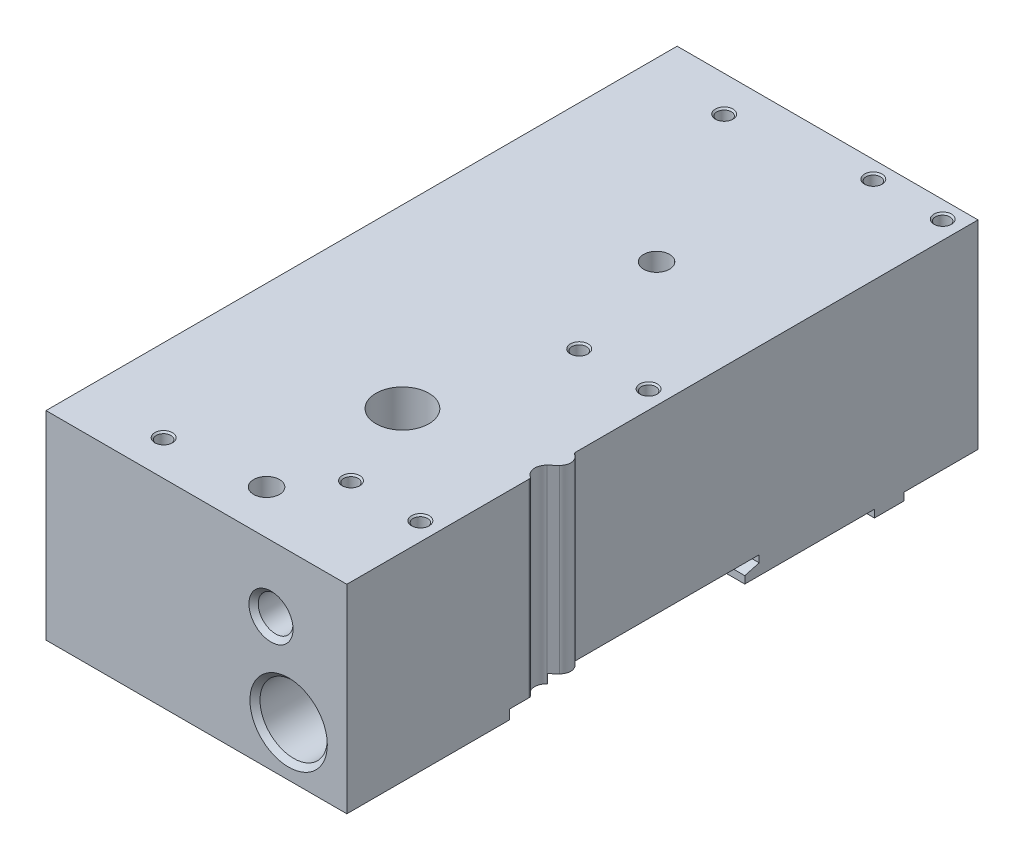
from build123d import *

# Parameters (mm, degrees)
BOSS_EXTRUDE1_DEPTH     = 33.8
CUT_EXTRUDE1_DEPTH      = 40
CUT_EXTRUDE1_DEPTH_BACK = 40
SKETCH13_R              = 4
BOSS_EXTRUDE2_DEPTH     = 1.3
SKETCH14_R              = 4
BOSS_EXTRUDE3_DEPTH     = 1.3
SKETCH15_W              = 2.2
SKETCH15_H              = 35.1
SKETCH17_W              = 2.2
SKETCH17_H              = 35.1
SKETCH18_W              = 2.5
SKETCH18_H              = 5
BOSS_EXTRUDE4_DEPTH     = 1.5
SKETCH19_W              = 2
SKETCH19_H              = 5
BOSS_EXTRUDE5_DEPTH     = 1.5


with BuildPart() as part:
    # Sketch1 → Boss-Extrude1 (new body)
    with BuildSketch(Plane(origin=(0, 1.3, 0), x_dir=(1, 0, 0), z_dir=(0, 1, 0))):
        with BuildLine():
            Line((-12.75, -53.65), (38.4, -53.65))
            Line((38.4, -53.65), (38.4, -22.654162541))
            ThreePointArc((38.4, -22.654162541), (38.338748223, -22.414370972), (38.170000014, -22.233330042))
            ThreePointArc((38.170000014, -22.233330042), (37.258228535, -20.731235846), (37.883912522, -19.089245057))
            Line((37.883912522, -19.089245057), (38.97947873, -18.064679449))
            ThreePointArc((38.97947873, -18.064679449), (39.538283152, -16.544955205), (38.649999929, -15.191154232))
            ThreePointArc((38.649999929, -15.191154232), (38.466987278, -15.008141536), (38.4, -14.758141571))
            Line((38.4, -14.758141571), (38.4, 53.65))
            Line((38.4, 53.65), (-12.75, 53.65))
            Line((-12.75, 53.65), (-12.75, -53.65))
        make_face()
    extrude(amount=BOSS_EXTRUDE1_DEPTH)

    # Sketch2 → Cut-Extrude1 (cut, two sides)
    with BuildSketch(Plane(origin=(0, 0, 0), x_dir=(0, 0, -1), z_dir=(1, 0, 0))) as cut_extrude1_sk:
        Polygon((-26, 2.9), (-26, -8.174443219), (14, -7.963716906), (14, 2.543524479), (16.45, 3.2), (16.45, 4.4), (-19.05, 4.4), (-19.05, 2.9), align=None)
    extrude(amount=CUT_EXTRUDE1_DEPTH, mode=Mode.SUBTRACT)
    extrude(cut_extrude1_sk.sketch, amount=-CUT_EXTRUDE1_DEPTH_BACK, mode=Mode.SUBTRACT)

    # Sketch3 → Cut-Revolve1 (revolve, cut)
    with BuildSketch(Plane(origin=(28.5, 0, 0), x_dir=(0, 0, -1), z_dir=(1, 0, 0))):
        Polygon((-53.65, 9.8), (-53.65, 16.3785), (-52.794, 15.5225), (-35.65, 15.5225), (-35.65, 9.8), align=None)
    revolve(axis=Axis((28.5, 9.8, 35.65), (0, 0, 1)), mode=Mode.SUBTRACT)

    # Sketch4 → Cut-Revolve2 (revolve, cut)
    with BuildSketch(Plane(origin=(25.5, 0, 0), x_dir=(0, 0, -1), z_dir=(1, 0, 0))):
        Polygon((-53.65, 23.9), (-53.65, 27.65), (-52.86, 26.86), (-44.65, 26.86), (-44.65, 23.9), align=None)
    revolve(axis=Axis((25.5, 23.9, 44.65), (0, 0, 1)), mode=Mode.SUBTRACT)

    # Sketch5 → Cut-Revolve3 (revolve, cut)
    with BuildSketch(Plane(origin=(1.25, 0, 0), x_dir=(0, 0, -1), z_dir=(1, 0, 0))):
        Polygon((47.65, 35.1), (49.15, 35.1), (48.8795, 34.8295), (48.8795, 30.1), (47.65, 30.1), align=None)
    revolve(axis=Axis((1.25, 30.1, -47.65), (0, 1, 0)), mode=Mode.SUBTRACT)

    # Sketch6 → Cut-Revolve4 (revolve, cut)
    with BuildSketch(Plane(origin=(1.25, 0, 0), x_dir=(0, 0, -1), z_dir=(1, 0, 0))):
        Polygon((-47.65, 35.1), (-46.15, 35.1), (-46.4205, 34.8295), (-46.4205, 30.1), (-47.65, 30.1), align=None)
    revolve(axis=Axis((1.25, 30.1, 47.65), (0, 1, 0)), mode=Mode.SUBTRACT)

    # Sketch7 → Cut-Revolve5 (revolve, cut)
    with BuildSketch(Plane(origin=(23.5, 0, 0), x_dir=(0, 0, -1), z_dir=(1, 0, 0))):
        Polygon((-38.05, 35.1), (-36.55, 35.1), (-36.8205, 34.8295), (-36.8205, 30.1), (-38.05, 30.1), align=None)
    revolve(axis=Axis((23.5, 30.1, 38.05), (0, 1, 0)), mode=Mode.SUBTRACT)

    # Sketch8 → Cut-Revolve6 (revolve, cut)
    with BuildSketch(Plane(origin=(23.5, 0, 0), x_dir=(0, 0, -1), z_dir=(1, 0, 0))):
        Polygon((0.75, 35.1), (2.25, 35.1), (1.9795, 34.8295), (1.9795, 30.1), (0.75, 30.1), align=None)
    revolve(axis=Axis((23.5, 30.1, -0.75), (0, 1, 0)), mode=Mode.SUBTRACT)

    # Sketch9 → Cut-Revolve7 (revolve, cut)
    with BuildSketch(Plane(origin=(23.5, 0, 0), x_dir=(0, 0, -1), z_dir=(1, 0, 0))):
        Polygon((50.75, 35.1), (52.25, 35.1), (51.9795, 34.8295), (51.9795, 30.1), (50.75, 30.1), align=None)
    revolve(axis=Axis((23.5, 30.1, -50.75), (0, 1, 0)), mode=Mode.SUBTRACT)

    # Sketch10 → Cut-Revolve8 (revolve, cut)
    with BuildSketch(Plane(origin=(35.3, 0, 0), x_dir=(0, 0, -1), z_dir=(1, 0, 0))):
        Polygon((-38.05, 35.1), (-36.55, 35.1), (-36.8205, 34.8295), (-36.8205, 30.1), (-38.05, 30.1), align=None)
    revolve(axis=Axis((35.3, 30.1, 38.05), (0, 1, 0)), mode=Mode.SUBTRACT)

    # Sketch11 → Cut-Revolve9 (revolve, cut)
    with BuildSketch(Plane(origin=(35.3, 0, 0), x_dir=(0, 0, -1), z_dir=(1, 0, 0))):
        Polygon((0.75, 35.1), (2.25, 35.1), (1.9795, 34.8295), (1.9795, 30.1), (0.75, 30.1), align=None)
    revolve(axis=Axis((35.3, 30.1, -0.75), (0, 1, 0)), mode=Mode.SUBTRACT)

    # Sketch12 → Cut-Revolve10 (revolve, cut)
    with BuildSketch(Plane(origin=(35.3, 0, 0), x_dir=(0, 0, -1), z_dir=(1, 0, 0))):
        Polygon((50.75, 35.1), (52.25, 35.1), (51.9795, 34.8295), (51.9795, 30.1), (50.75, 30.1), align=None)
    revolve(axis=Axis((35.3, 30.1, -50.75), (0, 1, 0)), mode=Mode.SUBTRACT)

    # Sketch13 → Boss-Extrude2 (add)
    with BuildSketch(Plane(origin=(0, 1.3, 0), x_dir=(-1, 0, 0), z_dir=(0, -1, 0))):
        with Locations((-17.65, -46.15)):
            Circle(SKETCH13_R)
    extrude(amount=BOSS_EXTRUDE2_DEPTH)

    # Sketch14 → Boss-Extrude3 (add)
    with BuildSketch(Plane(origin=(0, 1.3, 0), x_dir=(-1, 0, 0), z_dir=(0, -1, 0))):
        with Locations((-17.65, 20.15)):
            Circle(SKETCH14_R)
    extrude(amount=BOSS_EXTRUDE3_DEPTH)

    # Sketch15 → Cut-Revolve11 (revolve, cut)
    with BuildSketch(Plane(origin=(17.25, 0, 0), x_dir=(0, 0, -1), z_dir=(1, 0, 0))):
        with Locations((-45.05, 17.55)):
            Rectangle(SKETCH15_W, SKETCH15_H)
    revolve(axis=Axis((17.25, 0, 46.15), (0, 1, 0)), mode=Mode.SUBTRACT)

    # Sketch16 → Cut-Revolve12 (revolve, cut)
    with BuildSketch(Plane(origin=(17.25, 0, 0), x_dir=(0, 0, -1), z_dir=(1, 0, 0))):
        Polygon((-23.05, 35.1), (-18.55, 35.1), (-18.55, 10.1), (-20.85, 10.1), (-20.85, 0), (-23.05, 0), align=None)
    revolve(axis=Axis((17.25, 0, 23.05), (0, 1, 0)), mode=Mode.SUBTRACT)

    # Sketch17 → Cut-Revolve13 (revolve, cut)
    with BuildSketch(Plane(origin=(17.25, 0, 0), x_dir=(0, 0, -1), z_dir=(1, 0, 0))):
        with Locations((21.25, 17.55)):
            Rectangle(SKETCH17_W, SKETCH17_H)
    revolve(axis=Axis((17.25, 0, -20.15), (0, 1, 0)), mode=Mode.SUBTRACT)

    # Sketch18 → Boss-Extrude4 (add)
    with BuildSketch(Plane(origin=(0, 0, 0), x_dir=(1, 0, 0), z_dir=(0, 1, 0))):
        with Locations((37.15, 38.55)):
            Rectangle(SKETCH18_W, SKETCH18_H)
    extrude(amount=BOSS_EXTRUDE4_DEPTH)

    # Sketch19 → Boss-Extrude5 (add)
    with BuildSketch(Plane(origin=(0, 0, 0), x_dir=(1, 0, 0), z_dir=(0, 1, 0))):
        with Locations((-3.65, 38.55)):
            Rectangle(SKETCH19_W, SKETCH19_H)
    extrude(amount=BOSS_EXTRUDE5_DEPTH)


solid = part.part
